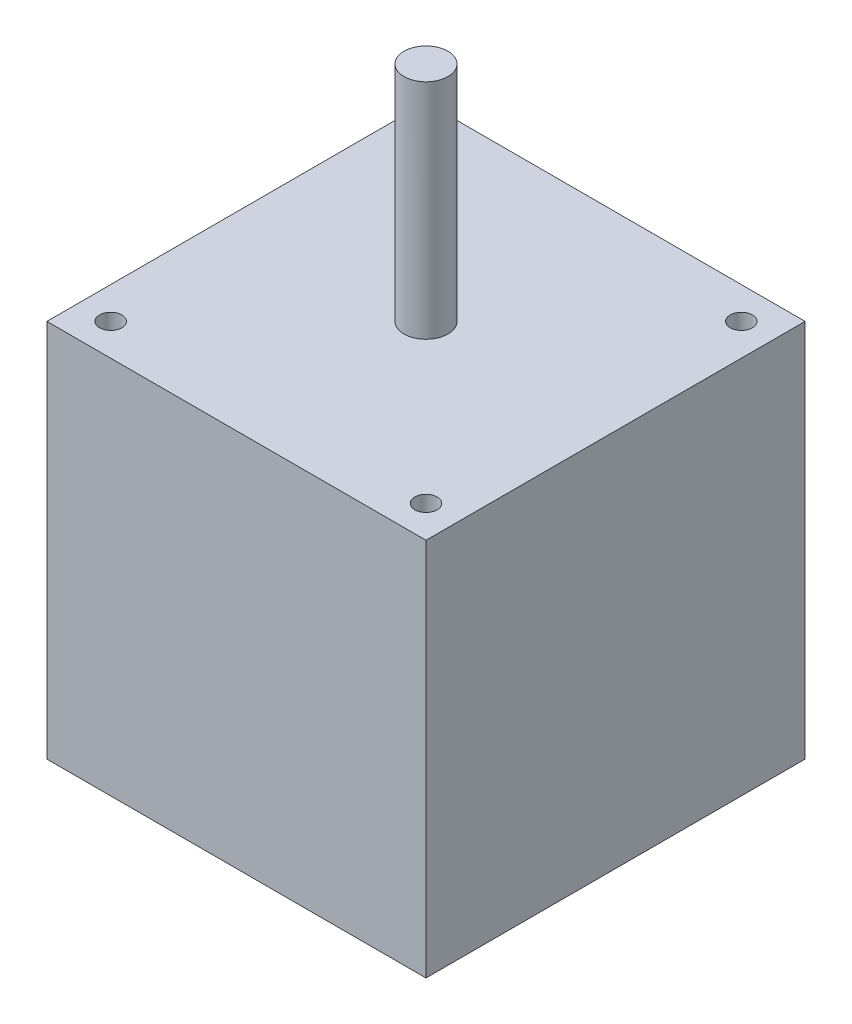
from build123d import *

# Parameters (mm, degrees)
SKETCH1_W            = 43.18
SKETCH1_H            = 43.18
BOSS_EXTRUDE1_DEPTH  = 43.18
SKETCH2_R            = 2.5
BOSS_EXTRUDE2_DEPTH  = 25.4
SKETCH3_R            = 1.27
CUT_EXTRUDE1_DEPTH   = 43.18
LPATTERN1_COUNT      = 2
LPATTERN1_PITCH      = 35.9156
LPATTERN1_COUNT_DIR2 = 2
LPATTERN1_PITCH_DIR2 = 35.9156


with BuildPart() as part:
    # Sketch1 → Boss-Extrude1 (new body)
    with BuildSketch(Plane(origin=(0, 0, 0), x_dir=(1, 0, 0), z_dir=(0, 1, 0))):
        Rectangle(SKETCH1_W, SKETCH1_H)
    extrude(amount=BOSS_EXTRUDE1_DEPTH)

    # Sketch2 → Boss-Extrude2 (add)
    with BuildSketch(Plane(origin=(0, 43.18, 0), x_dir=(1, 0, 0), z_dir=(0, 1, 0))):
        Circle(SKETCH2_R)
    extrude(amount=BOSS_EXTRUDE2_DEPTH)

    # Sketch3 → Cut-Extrude1 (cut)
    with BuildSketch(Plane(origin=(0, 43.18, 0), x_dir=(1, 0, 0), z_dir=(0, 1, 0))):
        with Locations((-17.960512242, 17.960512242)):
            Circle(SKETCH3_R)
    cut_extrude1 = extrude(amount=-CUT_EXTRUDE1_DEPTH, mode=Mode.SUBTRACT)

    # LPattern1: Cut-Extrude1 2 × 2
    with Locations(*[(i * LPATTERN1_PITCH, 0, j * LPATTERN1_PITCH_DIR2) for i in range(LPATTERN1_COUNT) for j in range(LPATTERN1_COUNT_DIR2) if (i, j) != (0, 0)]):
        add(cut_extrude1, mode=Mode.SUBTRACT)


solid = part.part
